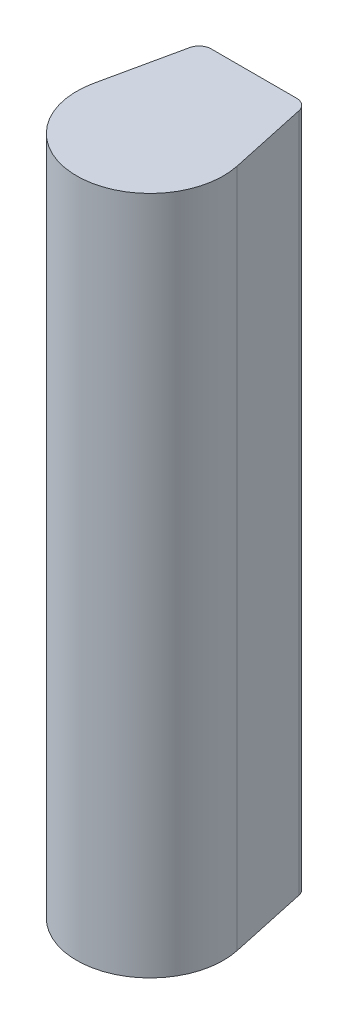
from build123d import *
from build123d.topology import SkipClean

# Parameters (mm, degrees)
EXTRUDE1_DEPTH = 50.8
FILLET1_R      = 2.54
EXTRUDE2_DEPTH = 90.354547646


with BuildPart() as part:
    # Sketch5 → Extrude1 (new body)
    with BuildSketch(Plane(origin=(0, 0, 0), x_dir=(1, 0, 0), z_dir=(0, 1, 0))):
        with BuildLine():
            Line((-10.922, 21.59), (10.922, 21.59))
            Line((10.922, 21.59), (14.895447762, 3.222302897))
            ThreePointArc((14.895447762, 3.222302897), (0, -15.24), (-14.895447762, 3.222302897))
            Line((-14.895447762, 3.222302897), (-10.922, 21.59))
        make_face()
    extrude(amount=EXTRUDE1_DEPTH)

    # Fillet1
    fillet1_edges = [part.edges().sort_by_distance(p)[0] for p in [
        (-10.922, 25.4, -21.59),
        (10.922, 25.4, -21.59),
    ]]
    fillet(fillet1_edges, radius=FILLET1_R)

    # Sketch10 → Extrude2 (add)
    with SkipClean():  # the faces are left unmerged after this step: merging them gives an invalid solid
        with BuildSketch(Plane(origin=(0, 50.8, 0), x_dir=(1, 0, 0), z_dir=(0, 1, 0))):
            with BuildLine():
                Line((8.8727195, 21.59), (-8.8727195, 21.59))
                ThreePointArc((-8.8727195, 21.59), (-10.467632001, 21.026829308), (-11.355294127, 19.587050483))
                Line((-11.355294127, 19.587050483), (-14.895447762, 3.222302897))
                ThreePointArc((-14.895447762, 3.222302897), (0, -15.24), (14.895447762, 3.222302897))
                Line((14.895447762, 3.222302897), (11.355294127, 19.587050483))
                ThreePointArc((11.355294127, 19.587050483), (10.467632001, 21.026829308), (8.8727195, 21.59))
            make_face()
        extrude(amount=EXTRUDE2_DEPTH)


solid = part.part
